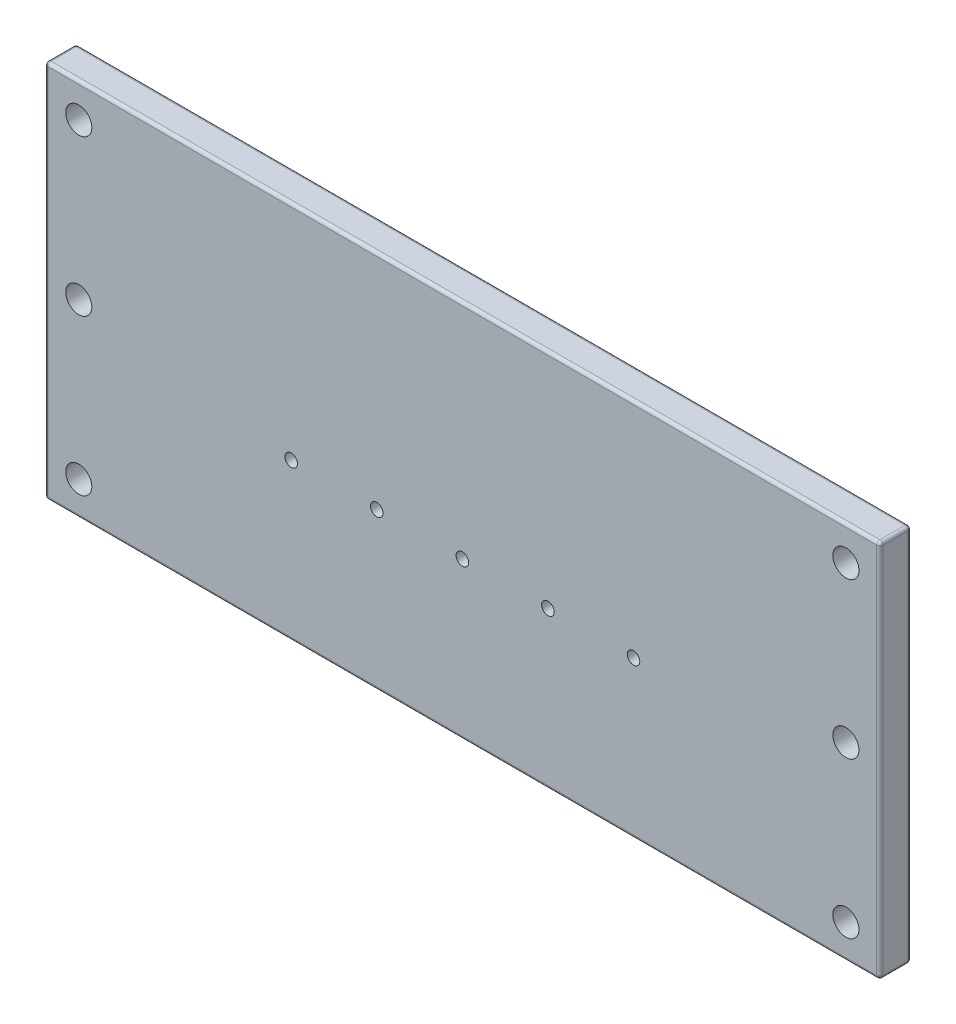
from build123d import *

# Parameters (mm, degrees)
SKETCH1_W            = 800
SKETCH1_H            = 363
BOSS_EXTRUDE1_DEPTH  = 30
SKETCH2_R            = 12.5
CUT_EXTRUDE1_DEPTH   = 30
LPATTERN1_COUNT      = 3
LPATTERN1_PITCH      = 149
LPATTERN1_COUNT_DIR2 = 2
LPATTERN1_PITCH_DIR2 = 735
SKETCH3_R            = 6
CUT_EXTRUDE2_DEPTH   = 20
LPATTERN2_COUNT      = 5
LPATTERN2_PITCH      = 82
SKETCH4_R            = 5
CUT_EXTRUDE3_DEPTH   = 18
LPATTERN3_COUNT      = 10
LPATTERN3_PITCH      = 68.33
FILLET1_R            = 3


with BuildPart() as part:
    # Sketch1 → Boss-Extrude1 (new body)
    with BuildSketch(Plane.XY):
        with Locations((400, 181.5)):
            Rectangle(SKETCH1_W, SKETCH1_H)
    extrude(amount=BOSS_EXTRUDE1_DEPTH)

    # Sketch2 → Cut-Extrude1 (cut)
    with BuildSketch(Plane.XY.offset(30)):
        with Locations((32.5, 32.5)):
            Circle(SKETCH2_R)
    cut_extrude1 = extrude(amount=-CUT_EXTRUDE1_DEPTH, mode=Mode.SUBTRACT)

    # LPattern1: Cut-Extrude1 3 × 2
    with Locations(*[(j * LPATTERN1_PITCH_DIR2, i * LPATTERN1_PITCH, 0) for i in range(LPATTERN1_COUNT) for j in range(LPATTERN1_COUNT_DIR2) if (i, j) != (0, 0)]):
        add(cut_extrude1, mode=Mode.SUBTRACT)

    # Sketch3 → Cut-Extrude2 (cut)
    with BuildSketch(Plane.XY.offset(30)):
        with Locations((236, 150)):
            Circle(SKETCH3_R)
    cut_extrude2 = extrude(amount=-CUT_EXTRUDE2_DEPTH, mode=Mode.SUBTRACT)

    # LPattern2: Cut-Extrude2 ×5
    with Locations(*[(i * LPATTERN2_PITCH, 0, 0) for i in range(1, LPATTERN2_COUNT)]):
        add(cut_extrude2, mode=Mode.SUBTRACT)

    # Sketch4 → Cut-Extrude3 (cut)
    with BuildSketch(Plane.XZ):
        with Locations((92.53, 10)):
            Circle(SKETCH4_R)
    cut_extrude3 = extrude(amount=-CUT_EXTRUDE3_DEPTH, mode=Mode.SUBTRACT)

    # LPattern3: Cut-Extrude3 ×10
    with Locations(*[(i * LPATTERN3_PITCH, 0, 0) for i in range(1, LPATTERN3_COUNT)]):
        add(cut_extrude3, mode=Mode.SUBTRACT)

    # Fillet1
    fillet1_edges = [part.edges().sort_by_distance(p)[0] for p in [
        (800, 181.5, 30),
        (400, 363, 30),
        (0, 181.5, 30),
        (400, 363, 0),
        (800, 181.5, 0),
        (400, 0, 0),
        (0, 181.5, 0),
        (0, 363, 15),
        (800, 363, 15),
        (800, 0, 15),
        (0, 0, 15),
        (400, 0, 30),
    ]]
    fillet(fillet1_edges, radius=FILLET1_R)


solid = part.part
